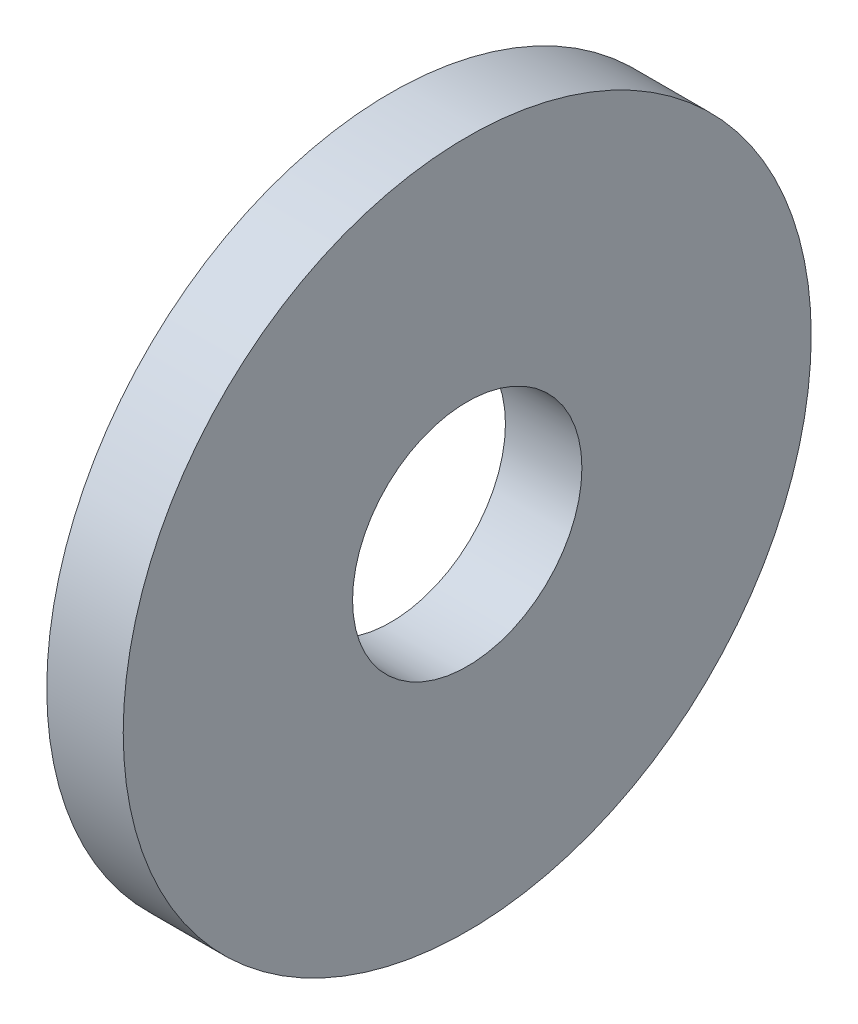
from build123d import *

# Parameters (mm, degrees)
SKETCH1_R           = 9
BOSS_EXTRUDE1_DEPTH = 2
SKETCH2_R           = 3
CUT_EXTRUDE1_DEPTH  = 3


with BuildPart() as part:
    # Sketch1 → Boss-Extrude1 (new body)
    with BuildSketch(Plane(origin=(0, 0, 0), x_dir=(0, 0, -1), z_dir=(1, 0, 0))):
        Circle(SKETCH1_R)
    extrude(amount=BOSS_EXTRUDE1_DEPTH)

    # Sketch2 → Cut-Extrude1 (cut, through all)
    with BuildSketch(Plane(origin=(2, 0, 0), x_dir=(0, 0, -1), z_dir=(1, 0, 0))):
        Circle(SKETCH2_R)
    extrude(amount=-CUT_EXTRUDE1_DEPTH, mode=Mode.SUBTRACT)


solid = part.part
